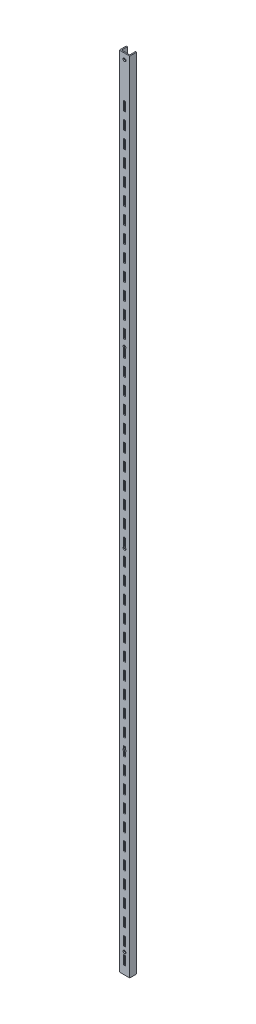
from build123d import *

# Parameters (mm, degrees)
BOSS_EXTRUDE1_DEPTH = 1219.2
SKETCH2_W           = 2.64
SKETCH2_H           = 14
CUT_EXTRUDE1_DEPTH  = 2.66
SKETCH3_R           = 2.195
CUT_EXTRUDE2_DEPTH  = 2.66


with BuildPart() as part:
    # Sketch1 → Boss-Extrude1 (new body)
    with BuildSketch(Plane(origin=(0, 0, 0), x_dir=(1, 0, 0), z_dir=(0, 1, 0))):
        Polygon((0, 0), (0, 10.69), (1.66, 10.69), (1.66, 1.66), (14.34, 1.66), (14.34, 10.69), (16, 10.69), (16, 0), align=None)
    extrude(amount=BOSS_EXTRUDE1_DEPTH)

    # Sketch2 → Cut-Extrude1 (cut, through all)
    with BuildSketch(Plane(origin=(0, 0, -1.66), x_dir=(-1, 0, 0), z_dir=(0, 0, -1))):
        with Locations((-8, 1148.99)):
            Rectangle(SKETCH2_W, SKETCH2_H)
        with Locations((-8, 1123.89)):
            Rectangle(SKETCH2_W, SKETCH2_H)
        with Locations((-8, 1098.79)):
            Rectangle(SKETCH2_W, SKETCH2_H)
        with Locations((-8, 1073.69)):
            Rectangle(SKETCH2_W, SKETCH2_H)
        with Locations((-8, 1048.59)):
            Rectangle(SKETCH2_W, SKETCH2_H)
        with Locations((-8, 1023.49)):
            Rectangle(SKETCH2_W, SKETCH2_H)
        with Locations((-8, 998.39)):
            Rectangle(SKETCH2_W, SKETCH2_H)
        with Locations((-8, 973.29)):
            Rectangle(SKETCH2_W, SKETCH2_H)
        with Locations((-8, 948.19)):
            Rectangle(SKETCH2_W, SKETCH2_H)
        with Locations((-8, 923.09)):
            Rectangle(SKETCH2_W, SKETCH2_H)
        with Locations((-8, 897.99)):
            Rectangle(SKETCH2_W, SKETCH2_H)
        with Locations((-8, 872.89)):
            Rectangle(SKETCH2_W, SKETCH2_H)
        with Locations((-8, 847.79)):
            Rectangle(SKETCH2_W, SKETCH2_H)
        with Locations((-8, 822.69)):
            Rectangle(SKETCH2_W, SKETCH2_H)
        with Locations((-8, 797.59)):
            Rectangle(SKETCH2_W, SKETCH2_H)
        with Locations((-8, 772.49)):
            Rectangle(SKETCH2_W, SKETCH2_H)
        with Locations((-8, 747.39)):
            Rectangle(SKETCH2_W, SKETCH2_H)
        with Locations((-8, 722.29)):
            Rectangle(SKETCH2_W, SKETCH2_H)
        with Locations((-8, 697.19)):
            Rectangle(SKETCH2_W, SKETCH2_H)
        with Locations((-8, 672.09)):
            Rectangle(SKETCH2_W, SKETCH2_H)
        with Locations((-8, 646.99)):
            Rectangle(SKETCH2_W, SKETCH2_H)
        with Locations((-8, 621.89)):
            Rectangle(SKETCH2_W, SKETCH2_H)
        with Locations((-8, 596.79)):
            Rectangle(SKETCH2_W, SKETCH2_H)
        with Locations((-8, 571.69)):
            Rectangle(SKETCH2_W, SKETCH2_H)
        with Locations((-8, 546.59)):
            Rectangle(SKETCH2_W, SKETCH2_H)
        with Locations((-8, 521.49)):
            Rectangle(SKETCH2_W, SKETCH2_H)
        with Locations((-8, 496.39)):
            Rectangle(SKETCH2_W, SKETCH2_H)
        with Locations((-8, 471.29)):
            Rectangle(SKETCH2_W, SKETCH2_H)
        with Locations((-8, 446.19)):
            Rectangle(SKETCH2_W, SKETCH2_H)
        with Locations((-8, 421.09)):
            Rectangle(SKETCH2_W, SKETCH2_H)
        with Locations((-8, 395.99)):
            Rectangle(SKETCH2_W, SKETCH2_H)
        with Locations((-8, 370.89)):
            Rectangle(SKETCH2_W, SKETCH2_H)
        with Locations((-8, 345.79)):
            Rectangle(SKETCH2_W, SKETCH2_H)
        with Locations((-8, 320.69)):
            Rectangle(SKETCH2_W, SKETCH2_H)
        with Locations((-8, 295.59)):
            Rectangle(SKETCH2_W, SKETCH2_H)
        with Locations((-8, 270.49)):
            Rectangle(SKETCH2_W, SKETCH2_H)
        with Locations((-8, 245.39)):
            Rectangle(SKETCH2_W, SKETCH2_H)
        with Locations((-8, 220.29)):
            Rectangle(SKETCH2_W, SKETCH2_H)
        with Locations((-8, 195.19)):
            Rectangle(SKETCH2_W, SKETCH2_H)
        with Locations((-8, 170.09)):
            Rectangle(SKETCH2_W, SKETCH2_H)
        with Locations((-8, 144.99)):
            Rectangle(SKETCH2_W, SKETCH2_H)
        with Locations((-8, 119.89)):
            Rectangle(SKETCH2_W, SKETCH2_H)
        with Locations((-8, 94.79)):
            Rectangle(SKETCH2_W, SKETCH2_H)
        with Locations((-8, 69.69)):
            Rectangle(SKETCH2_W, SKETCH2_H)
        with Locations((-8, 44.59)):
            Rectangle(SKETCH2_W, SKETCH2_H)
        with Locations((-8, 19.49)):
            Rectangle(SKETCH2_W, SKETCH2_H)
    extrude(amount=-CUT_EXTRUDE1_DEPTH, mode=Mode.SUBTRACT)

    # Sketch3 → Cut-Extrude2 (cut, through all)
    with BuildSketch(Plane(origin=(0, 0, -1.66), x_dir=(-1, 0, 0), z_dir=(0, 0, -1))):
        with Locations((-8, 1210.325)):
            Circle(SKETCH3_R)
        with Locations((-8, 830.595)):
            Circle(SKETCH3_R)
        with Locations((-8, 563.895)):
            Circle(SKETCH3_R)
        with Locations((-8, 297.195)):
            Circle(SKETCH3_R)
        with Locations((-8, 30.495)):
            Circle(SKETCH3_R)
    extrude(amount=-CUT_EXTRUDE2_DEPTH, mode=Mode.SUBTRACT)


solid = part.part
